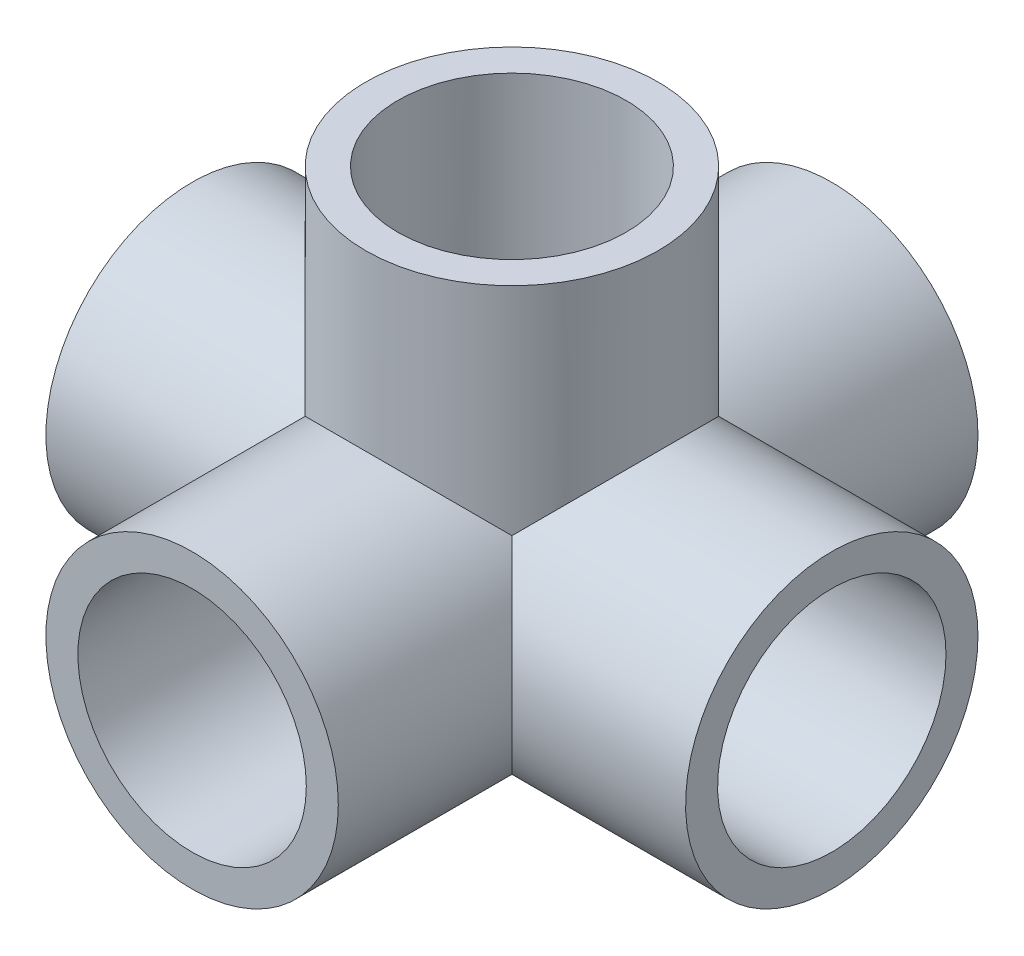
from build123d import *

# Parameters (mm, degrees)
SKETCH_1_R      = 16
SKETCH_1_R_2    = 12.5
EXTRUDE_1_DEPTH = 35
SKETCH_2_R      = 16
SKETCH_2_R_2    = 12.5
EXTRUDE_2_DEPTH = 35
SKETCH_4_R      = 16
SKETCH_4_R_2    = 12.5
EXTRUDE_3_DEPTH = 35


with BuildPart() as part:
    # 草图1 → 凸台-拉伸1 (new body, symmetric)
    with BuildSketch(Plane.XY):
        Circle(SKETCH_1_R)
        Circle(SKETCH_1_R_2, mode=Mode.SUBTRACT)
    extrude(amount=EXTRUDE_1_DEPTH, both=True)

    # 草图2 → 凸台-拉伸2 (add, symmetric)
    with BuildSketch(Plane(origin=(0, 0, 0), x_dir=(0, 0, -1), z_dir=(1, 0, 0))):
        Circle(SKETCH_2_R)
        Circle(SKETCH_2_R_2, mode=Mode.SUBTRACT)
    extrude(amount=EXTRUDE_2_DEPTH, both=True)

    # 草图4 → 凸台-拉伸3 (add)
    with BuildSketch(Plane(origin=(0, 0, 0), x_dir=(1, 0, 0), z_dir=(0, 1, 0))):
        Circle(SKETCH_4_R)
        Circle(SKETCH_4_R_2, mode=Mode.SUBTRACT)
    extrude(amount=EXTRUDE_3_DEPTH)


solid = part.part
